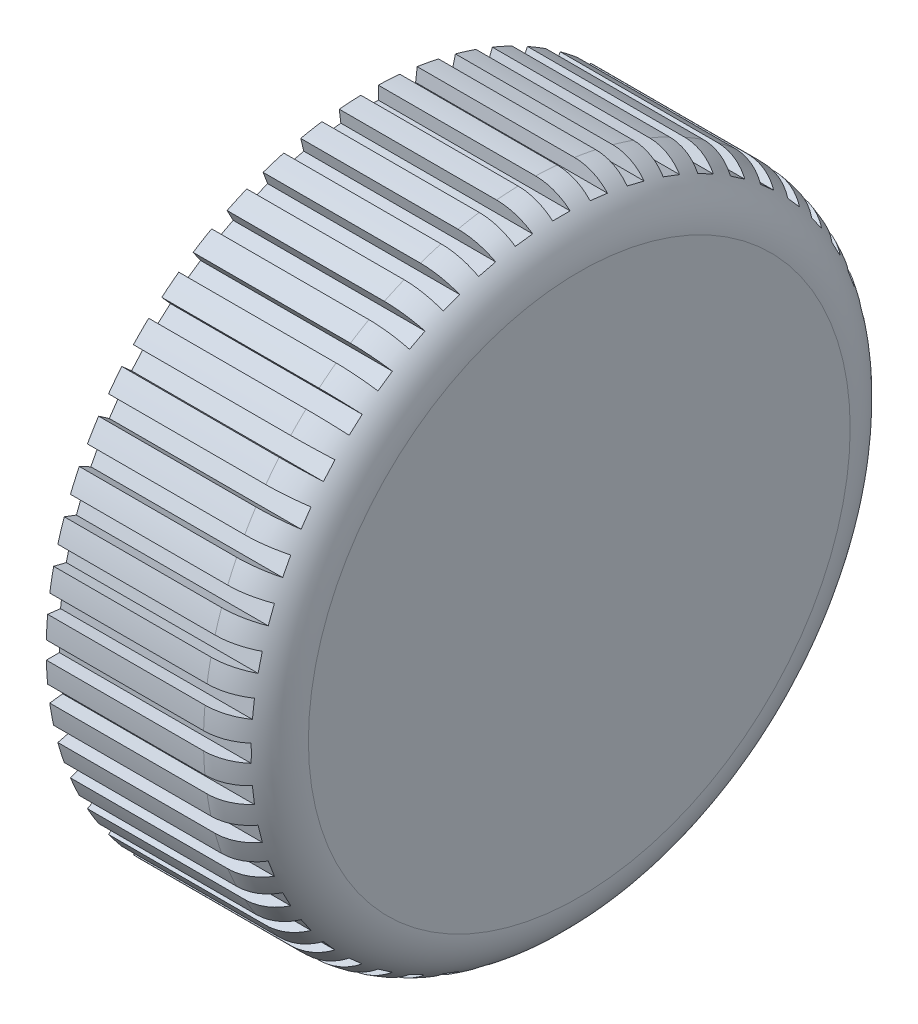
from build123d import *

# Parameters (mm, degrees)
SKETCH_2_W                  = 2
SKETCH_2_H                  = 3
SKETCH_2_W_2                = 3
SKETCH_2_H_2                = 2
CUT_EXTRUDE_2_DEPTH         = 25
EXTRUDE_1_REACH             = 38.986
SKETCH_3_R                  = 2.75
EXTRUDE_1_DIRECTION_2_REACH = 38.986
SKETCH_4_R                  = 6.474124247
CUT_EXTRUDE_3_DEPTH         = 33
CUT_EXTRUDE_3_DEPTH_BACK    = 33


with BuildPart() as part:
    # Эскиз1 → Повернуть1 (revolve)
    with BuildSketch(Plane.XY):
        with BuildLine():
            Line((0, 37), (0, 34.3))
            Line((0, 34.3), (16, 34.3))
            Line((16, 34.3), (16, 0))
            Line((16, 0), (24, 0))
            Line((24, 0), (24, 31))
            ThreePointArc((24, 31), (22.242640687, 35.242640687), (18, 37))
            Line((18, 37), (0, 37))
        make_face()
    revolve(axis=Axis((0, 0, 0), (1, 0, 0)))

    # Эскиз2 → Вырез-Вытянуть2 (cut, through all)
    with BuildSketch(Plane.ZY):
        with Locations((0, 37)):
            Rectangle(SKETCH_2_W, SKETCH_2_H)
        Polygon((5.633371064, 38.098754973), (5.271761023, 35.12062835), (3.286343275, 35.361701711), (3.647953316, 38.339828333), align=None)
        Polygon((10.184594892, 37.141944307), (9.4666479, 34.229118854), (7.524764265, 34.707750183), (8.242711258, 37.620575635), align=None)
        Polygon((14.587304394, 35.643520456), (13.523489733, 32.838471728), (11.653457247, 33.547681502), (12.717271908, 36.35273023), align=None)
        Polygon((18.777298149, 33.625333816), (17.383128633, 30.968965739), (15.612216582, 31.898412083), (17.006386098, 34.55478016), align=None)
        Polygon((22.693476615, 31.11681409), (20.989282375, 28.647862492), (19.343314643, 29.783991986), (21.047508883, 32.252943584), align=None)
        Polygon((26.27873309, 28.154541146), (24.289365116, 25.909008902), (22.792343619, 27.235254218), (24.781711594, 29.480786463), align=None)
        Polygon((29.480786463, 24.781711594), (27.235254218, 22.792343619), (25.909008902, 24.289365116), (28.154541146, 26.27873309), align=None)
        Polygon((32.252943584, 21.047508883), (29.783991986, 19.343314643), (28.647862492, 20.989282375), (31.11681409, 22.693476615), align=None)
        Polygon((34.55478016, 17.006386098), (31.898412083, 15.612216582), (30.968965739, 17.383128633), (33.625333816, 18.777298149), align=None)
        Polygon((36.35273023, 12.717271908), (33.547681502, 11.653457247), (32.838471728, 13.523489733), (35.643520456, 14.587304394), align=None)
        Polygon((37.620575635, 8.242711258), (34.707750183, 7.524764265), (34.229118854, 9.4666479), (37.141944307, 10.184594892), align=None)
        Polygon((38.339828333, 3.647953316), (35.361701711, 3.286343275), (35.12062835, 5.271761023), (38.098754973, 5.633371064), align=None)
        with Locations((37, 0)):
            Rectangle(SKETCH_2_W_2, SKETCH_2_H_2)
        Polygon((38.098754973, -5.633371064), (35.12062835, -5.271761023), (35.361701711, -3.286343275), (38.339828333, -3.647953316), align=None)
        Polygon((37.141944307, -10.184594892), (34.229118854, -9.4666479), (34.707750183, -7.524764265), (37.620575635, -8.242711258), align=None)
        Polygon((35.643520456, -14.587304394), (32.838471728, -13.523489733), (33.547681502, -11.653457247), (36.35273023, -12.717271908), align=None)
        Polygon((33.625333816, -18.777298149), (30.968965739, -17.383128633), (31.898412083, -15.612216582), (34.55478016, -17.006386098), align=None)
        Polygon((31.11681409, -22.693476615), (28.647862492, -20.989282375), (29.783991986, -19.343314643), (32.252943584, -21.047508883), align=None)
        Polygon((28.154541146, -26.27873309), (25.909008902, -24.289365116), (27.235254218, -22.792343619), (29.480786463, -24.781711594), align=None)
        Polygon((24.781711594, -29.480786463), (22.792343619, -27.235254218), (24.289365116, -25.909008902), (26.27873309, -28.154541146), align=None)
        Polygon((21.047508883, -32.252943584), (19.343314643, -29.783991986), (20.989282375, -28.647862492), (22.693476615, -31.11681409), align=None)
        Polygon((17.006386098, -34.55478016), (15.612216582, -31.898412083), (17.383128633, -30.968965739), (18.777298149, -33.625333816), align=None)
        Polygon((12.717271908, -36.35273023), (11.653457247, -33.547681502), (13.523489733, -32.838471728), (14.587304394, -35.643520456), align=None)
        Polygon((8.242711258, -37.620575635), (7.524764265, -34.707750183), (9.4666479, -34.229118854), (10.184594892, -37.141944307), align=None)
        Polygon((3.647953316, -38.339828333), (3.286343275, -35.361701711), (5.271761023, -35.12062835), (5.633371064, -38.098754973), align=None)
        with Locations((0, -37)):
            Rectangle(SKETCH_2_W, SKETCH_2_H)
        Polygon((-5.633371064, -38.098754973), (-5.271761023, -35.12062835), (-3.286343275, -35.361701711), (-3.647953316, -38.339828333), align=None)
        Polygon((-10.184594892, -37.141944307), (-9.4666479, -34.229118854), (-7.524764265, -34.707750183), (-8.242711258, -37.620575635), align=None)
        Polygon((-14.587304394, -35.643520456), (-13.523489733, -32.838471728), (-11.653457247, -33.547681502), (-12.717271908, -36.35273023), align=None)
        Polygon((-18.777298149, -33.625333816), (-17.383128633, -30.968965739), (-15.612216582, -31.898412083), (-17.006386098, -34.55478016), align=None)
        Polygon((-22.693476615, -31.11681409), (-20.989282375, -28.647862492), (-19.343314643, -29.783991986), (-21.047508883, -32.252943584), align=None)
        Polygon((-26.27873309, -28.154541146), (-24.289365116, -25.909008902), (-22.792343619, -27.235254218), (-24.781711594, -29.480786463), align=None)
        Polygon((-29.480786463, -24.781711594), (-27.235254218, -22.792343619), (-25.909008902, -24.289365116), (-28.154541146, -26.27873309), align=None)
        Polygon((-32.252943584, -21.047508883), (-29.783991986, -19.343314643), (-28.647862492, -20.989282375), (-31.11681409, -22.693476615), align=None)
        Polygon((-34.55478016, -17.006386098), (-31.898412083, -15.612216582), (-30.968965739, -17.383128633), (-33.625333816, -18.777298149), align=None)
        Polygon((-36.35273023, -12.717271908), (-33.547681502, -11.653457247), (-32.838471728, -13.523489733), (-35.643520456, -14.587304394), align=None)
        Polygon((-37.620575635, -8.242711258), (-34.707750183, -7.524764265), (-34.229118854, -9.4666479), (-37.141944307, -10.184594892), align=None)
        Polygon((-38.339828333, -3.647953316), (-35.361701711, -3.286343275), (-35.12062835, -5.271761023), (-38.098754973, -5.633371064), align=None)
        with Locations((-37, 0)):
            Rectangle(SKETCH_2_W_2, SKETCH_2_H_2)
        Polygon((-38.098754973, 5.633371064), (-35.12062835, 5.271761023), (-35.361701711, 3.286343275), (-38.339828333, 3.647953316), align=None)
        Polygon((-37.141944307, 10.184594892), (-34.229118854, 9.4666479), (-34.707750183, 7.524764265), (-37.620575635, 8.242711258), align=None)
        Polygon((-35.643520456, 14.587304394), (-32.838471728, 13.523489733), (-33.547681502, 11.653457247), (-36.35273023, 12.717271908), align=None)
        Polygon((-33.625333816, 18.777298149), (-30.968965739, 17.383128633), (-31.898412083, 15.612216582), (-34.55478016, 17.006386098), align=None)
        Polygon((-31.11681409, 22.693476615), (-28.647862492, 20.989282375), (-29.783991986, 19.343314643), (-32.252943584, 21.047508883), align=None)
        Polygon((-28.154541146, 26.27873309), (-25.909008902, 24.289365116), (-27.235254218, 22.792343619), (-29.480786463, 24.781711594), align=None)
        Polygon((-24.781711594, 29.480786463), (-22.792343619, 27.235254218), (-24.289365116, 25.909008902), (-26.27873309, 28.154541146), align=None)
        Polygon((-21.047508883, 32.252943584), (-19.343314643, 29.783991986), (-20.989282375, 28.647862492), (-22.693476615, 31.11681409), align=None)
        Polygon((-17.006386098, 34.55478016), (-15.612216582, 31.898412083), (-17.383128633, 30.968965739), (-18.777298149, 33.625333816), align=None)
        Polygon((-12.717271908, 36.35273023), (-11.653457247, 33.547681502), (-13.523489733, 32.838471728), (-14.587304394, 35.643520456), align=None)
        Polygon((-8.242711258, 37.620575635), (-7.524764265, 34.707750183), (-9.4666479, 34.229118854), (-10.184594892, 37.141944307), align=None)
        Polygon((-3.647953316, 38.339828333), (-3.286343275, 35.361701711), (-5.271761023, 35.12062835), (-5.633371064, 38.098754973), align=None)
    extrude(amount=-CUT_EXTRUDE_2_DEPTH, mode=Mode.SUBTRACT)

    # Эскиз3 → Бобышка-Вытянуть1 (add, up to next)
    with BuildSketch(Plane.XY, mode=Mode.PRIVATE) as extrude_1_sk1:
        with Locations((7, 0)):
            Circle(SKETCH_3_R)
    extrude_1_tool1 = extrude(extrude_1_sk1.sketch, amount=EXTRUDE_1_REACH, mode=Mode.PRIVATE) - part.part
    add(extrude_1_tool1.solids().sort_by_distance((7, 0, 0))[0])

    # Эскиз3 → Бобышка-Вытянуть1 direction 2 (add, up to next)
    with BuildSketch(Plane.XY, mode=Mode.PRIVATE) as extrude_1_direction_2_sk1:
        with Locations((7, 0)):
            Circle(SKETCH_3_R)
    extrude_1_direction_2_tool1 = extrude(extrude_1_direction_2_sk1.sketch, amount=-EXTRUDE_1_DIRECTION_2_REACH, mode=Mode.PRIVATE) - part.part
    add(extrude_1_direction_2_tool1.solids().sort_by_distance((7, 0, 0))[0])

    # Эскиз4 → Вырез-Вытянуть3 (cut, two sides)
    with BuildSketch(Plane.XY) as cut_extrude_3_sk:
        with Locations((7, 0)):
            Circle(SKETCH_4_R)
    extrude(amount=CUT_EXTRUDE_3_DEPTH, mode=Mode.SUBTRACT)
    extrude(cut_extrude_3_sk.sketch, amount=-CUT_EXTRUDE_3_DEPTH_BACK, mode=Mode.SUBTRACT)


solid = part.part
